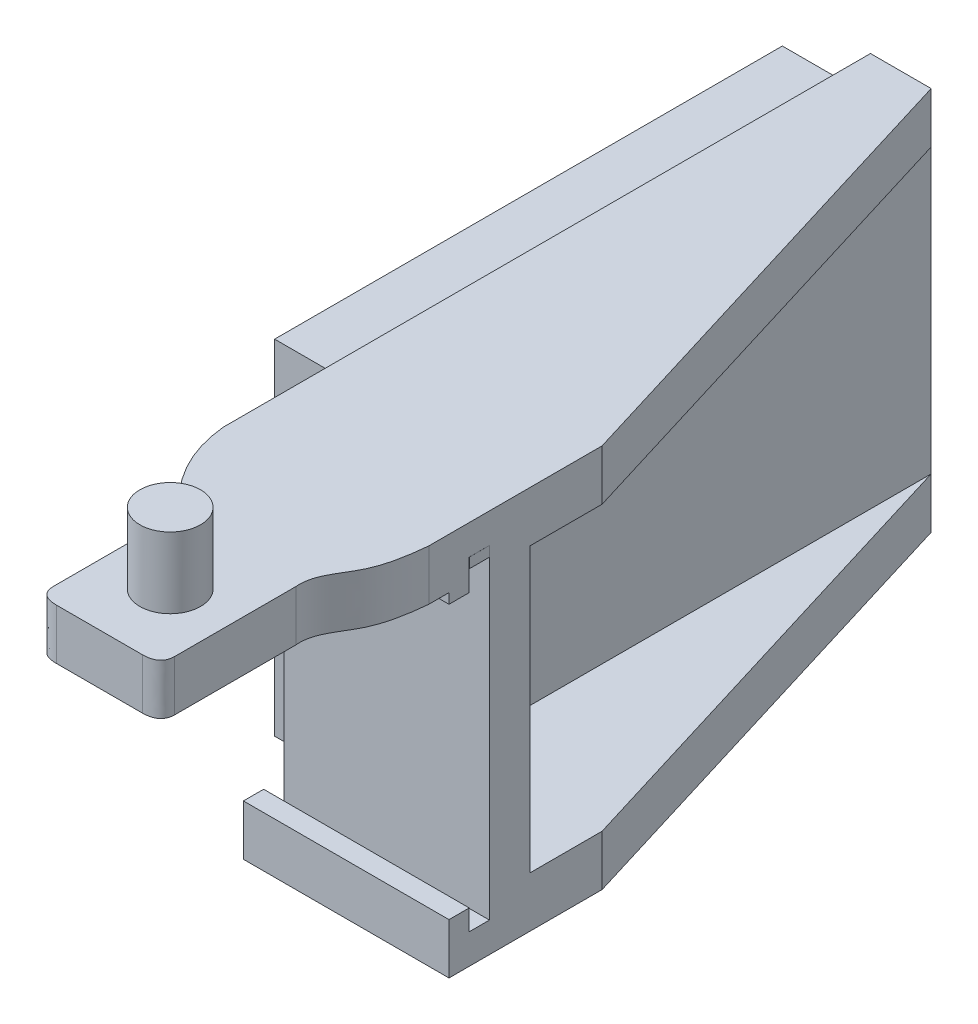
from build123d import *

# Parameters (mm, degrees)
SALIENTE_EXTRUIR1_DEPTH    = 19
CROQUIS2_W                 = 9.87256946
CROQUIS2_H                 = 14
CORTAR_EXTRUIR1_DEPTH      = 27
CORTAR_EXTRUIR2_DEPTH      = 11.163106866
CORTAR_EXTRUIR2_DEPTH_BACK = 1.0000001
CROQUIS11_W                = 1
CROQUIS11_H                = 1.020123201
CORTAR_EXTRUIR3_DEPTH      = 33
CROQUIS12_R                = 1.5
SALIENTE_EXTRUIR3_DEPTH    = 3.5
CROQUIS13_W                = 25.1
CROQUIS13_H                = 17
SALIENTE_EXTRUIR5_DEPTH    = 3.5
CROQUIS16_W                = 1
CROQUIS16_H                = 0.5
SALIENTE_EXTRUIR8_DEPTH    = 10.162
CROQUIS19_W                = 1
CROQUIS19_H                = 0.5
SALIENTE_EXTRUIR9_DEPTH    = 10.165


with BuildPart() as part:
    # Croquis1 → Saliente-Extruir1 (new body)
    with BuildSketch(Plane(origin=(0, 0, 0), x_dir=(1, 0, 0), z_dir=(0, 1, 0))):
        with BuildLine():
            Line((0, 30), (0, 0))
            Line((0, 0), (0, -2))
            add(Edge.make_bspline(
                [(0, -2), (0.244064913, -4.453043064), (2.060905279, -6.231862145)],
                knots=[0, 0, 0, 1, 1, 1], degree=2))
            add(Edge.make_bspline(
                [(2.060905279, -6.231862145), (2.507004014, -6.712573557), (2.617207224, -7.344647716)],
                knots=[0, 0, 0, 1, 1, 1], degree=2))
            Line((2.617207224, -7.344647716), (2.617207224, -13.018311654))
            add(Edge.make_bspline(
                [(2.617207224, -13.018311654), (2.630895377, -13.73499915), (3.489917654, -13.737380921)],
                knots=[0, 0, 0, 1, 1, 1], degree=2))
            Line((3.489917654, -13.737380921), (7.744496795, -13.737380921))
            add(Edge.make_bspline(
                [(8.617207224, -13.018311654), (8.603519071, -13.73499915), (7.744496795, -13.737380921)],
                knots=[0, 0, 0, 1, 1, 1], degree=2))
            Line((8.617207224, -13.018311654), (8.617207224, -7.018311654))
            add(Edge.make_bspline(
                [(8.617207224, -7.018311654), (8.52941254, -6.066211773), (9.815332332, -4.707225326), (10.076873528, -2.886889338), (10.163106766, -2)],
                knots=[0, 0, 0, 0, 0.490316762, 1, 1, 1, 1], degree=3))
            Line((10.163106766, -2), (10.163106766, 0))
            Line((10.163106766, 0), (10.163106766, 6.570533479))
            Line((10.163106766, 6.570533479), (3, 30))
            Line((3, 30), (0, 30))
        make_face()
    extrude(amount=SALIENTE_EXTRUIR1_DEPTH)

    # Croquis2 → Cortar-Extruir1 (cut)
    with BuildSketch(Plane(origin=(0, 0, -30), x_dir=(-1, 0, 0), z_dir=(0, 0, -1))):
        with Locations((-7.93628473, 9.5)):
            Rectangle(CROQUIS2_W, CROQUIS2_H)
    extrude(amount=-CORTAR_EXTRUIR1_DEPTH, mode=Mode.SUBTRACT)

    # Croquis10 → Cortar-Extruir2 (cut, two sides)
    with BuildSketch(Plane(origin=(0, 0, 0), x_dir=(0, 0, -1), z_dir=(1, 0, 0))) as cortar_extruir2_sk:
        Polygon((1, 2.5), (1, 16.5), (-13.737380921, 16.5), (-13.737380921, 0), (-1, 0), (-1, 2.5), align=None)
    extrude(amount=CORTAR_EXTRUIR2_DEPTH, mode=Mode.SUBTRACT)
    extrude(cortar_extruir2_sk.sketch, amount=-CORTAR_EXTRUIR2_DEPTH_BACK, mode=Mode.SUBTRACT)

    # Croquis11 → Cortar-Extruir3 (cut)
    with BuildSketch(Plane(origin=(0, 0, 0), x_dir=(0, 0, -1), z_dir=(1, 0, 0))):
        with Locations((0.5, 1.9899384)):
            Rectangle(CROQUIS11_W, CROQUIS11_H)
        with Locations((0.5, 17.010061601)):
            Rectangle(CROQUIS11_W, CROQUIS11_H)
    extrude(amount=CORTAR_EXTRUIR3_DEPTH, mode=Mode.SUBTRACT)

    # Croquis12 → Saliente-Extruir3 (add)
    with BuildSketch(Plane(origin=(0, 19, 0), x_dir=(1, 0, 0), z_dir=(0, 1, 0))):
        with Locations((5.617207224, -10.237380921)):
            Circle(CROQUIS12_R)
    extrude(amount=SALIENTE_EXTRUIR3_DEPTH)

    # Croquis13 → Saliente-Extruir5 (add)
    with BuildSketch(Plane.ZY):
        with Locations((-16.592912937, 9.5)):
            Rectangle(CROQUIS13_W, CROQUIS13_H)
    extrude(amount=SALIENTE_EXTRUIR5_DEPTH)

    # Croquis16 → Saliente-Extruir8 (add)
    with BuildSketch(Plane(origin=(10.163106766, 0, 0), x_dir=(0, 0, -1), z_dir=(1, 0, 0))):
        with Locations((-0.5, 16.25)):
            Rectangle(CROQUIS16_W, CROQUIS16_H)
    extrude(amount=-SALIENTE_EXTRUIR8_DEPTH)

    # Croquis19 → Saliente-Extruir9 (add)
    with BuildSketch(Plane.ZY):
        with Locations((-0.5, 17.270123201)):
            Rectangle(CROQUIS19_W, CROQUIS19_H)
    extrude(amount=-SALIENTE_EXTRUIR9_DEPTH)


solid = part.part
